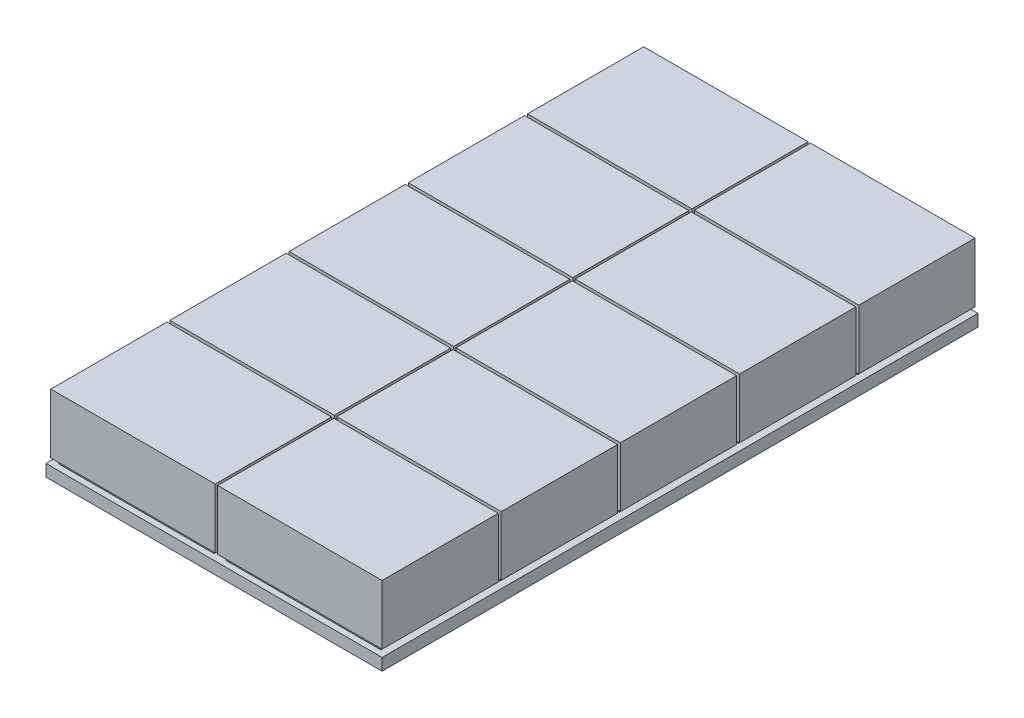
from build123d import *

# Parameters (mm, degrees)
SKETCH1_W                 = 71
SKETCH1_H                 = 250
BOSS_EXTRUDE1_DEPTH       = 5
SKETCH2_W                 = 65
SKETCH2_H                 = 45
BOSS_EXTRUDE3_DEPTH       = 2
LPATTERN1_COUNT           = 5
LPATTERN1_PITCH           = 50
SKETCH3_W                 = 69
SKETCH3_H                 = 48.754858224
BOSS_EXTRUDE8_DEPTH       = 25
LPATTERN5_COUNT           = 5
LPATTERN5_PITCH           = 50
LPATTERN6_COUNT           = 2
LPATTERN6_PITCH           = 70
LPATTERN6_COPY_1_SKETCH_W = 65
LPATTERN6_COPY_1_SKETCH_H = 45
LPATTERN6_COPY_1_DEPTH    = 2
LPATTERN6_COPY_2_SKETCH_W = 65
LPATTERN6_COPY_2_SKETCH_H = 45
LPATTERN6_COPY_2_DEPTH    = 2
LPATTERN6_COPY_3_SKETCH_W = 65
LPATTERN6_COPY_3_SKETCH_H = 45
LPATTERN6_COPY_3_DEPTH    = 2
LPATTERN6_COPY_4_SKETCH_W = 65
LPATTERN6_COPY_4_SKETCH_H = 45
LPATTERN6_COPY_4_DEPTH    = 2
LPATTERN6_COPY_5_SKETCH_W = 69
LPATTERN6_COPY_5_SKETCH_H = 48.754858224
LPATTERN6_COPY_5_DEPTH    = 25
LPATTERN6_COPY_6_SKETCH_W = 69
LPATTERN6_COPY_6_SKETCH_H = 48.754858224
LPATTERN6_COPY_6_DEPTH    = 25
LPATTERN6_COPY_7_SKETCH_W = 69
LPATTERN6_COPY_7_SKETCH_H = 48.754858224
LPATTERN6_COPY_7_DEPTH    = 25
LPATTERN6_COPY_8_SKETCH_W = 69
LPATTERN6_COPY_8_SKETCH_H = 48.754858224
LPATTERN6_COPY_8_DEPTH    = 25


with BuildPart() as part:
    # Sketch1 → Boss-Extrude1 (new body)
    with BuildSketch(Plane(origin=(0, 0, 0), x_dir=(1, 0, 0), z_dir=(0, 1, 0))):
        Rectangle(SKETCH1_W, SKETCH1_H)
    boss_extrude1 = extrude(amount=BOSS_EXTRUDE1_DEPTH)

    # Sketch2 → Boss-Extrude3 (add)
    with BuildSketch(Plane(origin=(0, 5, 0), x_dir=(1, 0, 0), z_dir=(0, 1, 0))):
        with Locations((0, -100)):
            Rectangle(SKETCH2_W, SKETCH2_H)
    boss_extrude3 = extrude(amount=BOSS_EXTRUDE3_DEPTH)

    # LPattern1: Boss-Extrude3 ×5
    with Locations(*[(0, 0, -i * LPATTERN1_PITCH) for i in range(1, LPATTERN1_COUNT)]):
        add(boss_extrude3)

    # Sketch3 → Boss-Extrude8 (add)
    with BuildSketch(Plane(origin=(0, 7, 0), x_dir=(1, 0, 0), z_dir=(0, 1, 0))):
        with Locations((0, -99.635002086)):
            Rectangle(SKETCH3_W, SKETCH3_H)
    boss_extrude8 = extrude(amount=BOSS_EXTRUDE8_DEPTH)

    # LPattern5: Boss-Extrude8 ×5
    with Locations(*[(0, 0, -i * LPATTERN5_PITCH) for i in range(1, LPATTERN5_COUNT)]):
        add(boss_extrude8)

    # LPattern6: Boss-Extrude1, Boss-Extrude3, Boss-Extrude8 ×2
    with Locations(*[(i * LPATTERN6_PITCH, 0, 0) for i in range(1, LPATTERN6_COUNT)]):
        add(boss_extrude1)
        add(boss_extrude3)
        add(boss_extrude8)

    # LPattern6 copy 1 sketch → LPattern6 copy 1 (add)
    with BuildSketch(Plane(origin=(70, 5, -50), x_dir=(1, 0, 0), z_dir=(0, 1, 0))):
        with Locations((0, -100)):
            Rectangle(LPATTERN6_COPY_1_SKETCH_W, LPATTERN6_COPY_1_SKETCH_H)
    extrude(amount=LPATTERN6_COPY_1_DEPTH)

    # LPattern6 copy 2 sketch → LPattern6 copy 2 (add)
    with BuildSketch(Plane(origin=(70, 5, -100), x_dir=(1, 0, 0), z_dir=(0, 1, 0))):
        with Locations((0, -100)):
            Rectangle(LPATTERN6_COPY_2_SKETCH_W, LPATTERN6_COPY_2_SKETCH_H)
    extrude(amount=LPATTERN6_COPY_2_DEPTH)

    # LPattern6 copy 3 sketch → LPattern6 copy 3 (add)
    with BuildSketch(Plane(origin=(70, 5, -150), x_dir=(1, 0, 0), z_dir=(0, 1, 0))):
        with Locations((0, -100)):
            Rectangle(LPATTERN6_COPY_3_SKETCH_W, LPATTERN6_COPY_3_SKETCH_H)
    extrude(amount=LPATTERN6_COPY_3_DEPTH)

    # LPattern6 copy 4 sketch → LPattern6 copy 4 (add)
    with BuildSketch(Plane(origin=(70, 5, -200), x_dir=(1, 0, 0), z_dir=(0, 1, 0))):
        with Locations((0, -100)):
            Rectangle(LPATTERN6_COPY_4_SKETCH_W, LPATTERN6_COPY_4_SKETCH_H)
    extrude(amount=LPATTERN6_COPY_4_DEPTH)

    # LPattern6 copy 5 sketch → LPattern6 copy 5 (add)
    with BuildSketch(Plane(origin=(70, 7, -50), x_dir=(1, 0, 0), z_dir=(0, 1, 0))):
        with Locations((0, -99.635002086)):
            Rectangle(LPATTERN6_COPY_5_SKETCH_W, LPATTERN6_COPY_5_SKETCH_H)
    extrude(amount=LPATTERN6_COPY_5_DEPTH)

    # LPattern6 copy 6 sketch → LPattern6 copy 6 (add)
    with BuildSketch(Plane(origin=(70, 7, -100), x_dir=(1, 0, 0), z_dir=(0, 1, 0))):
        with Locations((0, -99.635002086)):
            Rectangle(LPATTERN6_COPY_6_SKETCH_W, LPATTERN6_COPY_6_SKETCH_H)
    extrude(amount=LPATTERN6_COPY_6_DEPTH)

    # LPattern6 copy 7 sketch → LPattern6 copy 7 (add)
    with BuildSketch(Plane(origin=(70, 7, -150), x_dir=(1, 0, 0), z_dir=(0, 1, 0))):
        with Locations((0, -99.635002086)):
            Rectangle(LPATTERN6_COPY_7_SKETCH_W, LPATTERN6_COPY_7_SKETCH_H)
    extrude(amount=LPATTERN6_COPY_7_DEPTH)

    # LPattern6 copy 8 sketch → LPattern6 copy 8 (add)
    with BuildSketch(Plane(origin=(70, 7, -200), x_dir=(1, 0, 0), z_dir=(0, 1, 0))):
        with Locations((0, -99.635002086)):
            Rectangle(LPATTERN6_COPY_8_SKETCH_W, LPATTERN6_COPY_8_SKETCH_H)
    extrude(amount=LPATTERN6_COPY_8_DEPTH)


solid = part.part
